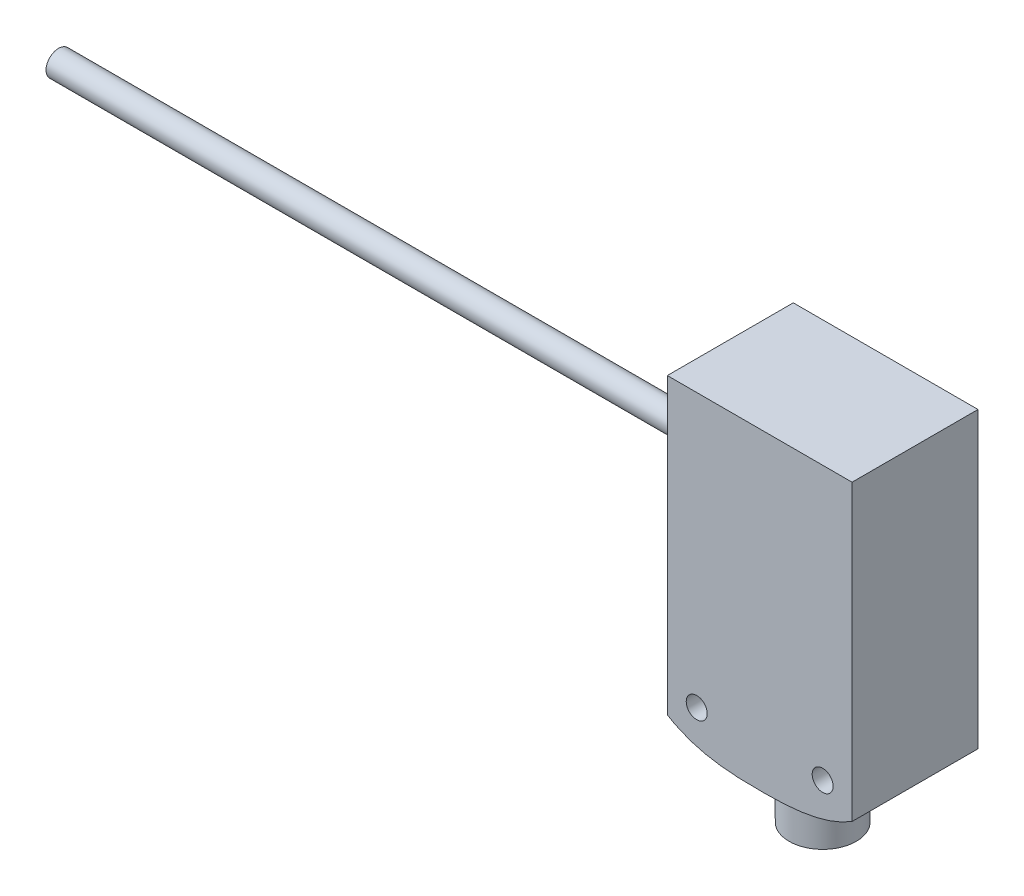
from build123d import *

# Parameters (mm, degrees)
ESQUISSE1_W             = 22
ESQUISSE1_H             = 44.3
ESQUISSE1_R             = 1.25
BOSS_EXTRU_1_DEPTH      = 15
ENL_V_MAT_EXTRU_1_DEPTH = 16
BOSS_EXTRU_2_REACH      = 46.3
ESQUISSE3_R             = 4
ENL_V_MAT_EXTRU_2_DEPTH = 0.1
ESQUISSE5_R             = 1.5
BOSS_EXTRU_3_DEPTH      = 80


with BuildPart() as part:
    # Esquisse1 → Boss.-Extru.1 (new body)
    with BuildSketch(Plane.XY):
        with Locations((0, 22.15)):
            Rectangle(ESQUISSE1_W, ESQUISSE1_H)
        with Locations((7.5, 11.8)):
            Circle(ESQUISSE1_R, mode=Mode.SUBTRACT)
        with Locations((-7.5, 11.8)):
            Circle(ESQUISSE1_R, mode=Mode.SUBTRACT)
    extrude(amount=BOSS_EXTRU_1_DEPTH)

    # Esquisse2 → Enlèv. mat.-Extru.1 (cut, through all)
    with BuildSketch(Plane.XY.offset(15)):
        with BuildLine():
            Line((-11, 9.3), (-11, 0))
            Line((-11, 0), (11, 0))
            Line((11, 0), (11, 9.3))
            add(Edge.make_bspline(
                [(-11, 9.3), (-7.625374572, 7.236730077), (0, 6.763269923), (7.625374572, 7.236730077), (11, 9.3)],
                knots=[0, 0, 0, 0, 0.5, 1, 1, 1, 1], degree=3))
        make_face()
    extrude(amount=-ENL_V_MAT_EXTRU_1_DEPTH, mode=Mode.SUBTRACT)

    # Esquisse3 → Boss.-Extru.2 (add, up to next)
    with BuildSketch(Plane(origin=(0, 0, 0), x_dir=(1, 0, 0), z_dir=(0, 1, 0)), mode=Mode.PRIVATE) as boss_extru_2_sk1:
        with Locations((0, -7.5)):
            Circle(ESQUISSE3_R)
    boss_extru_2_tool1 = extrude(boss_extru_2_sk1.sketch, amount=BOSS_EXTRU_2_REACH, mode=Mode.PRIVATE) - part.part
    add(boss_extru_2_tool1.solids().sort_by_distance((0, 0, 7.5))[0])

    # Esquisse4 → Enlèv. mat.-Extru.2 (cut)
    with BuildSketch(Plane.ZY.offset(11)):
        with BuildLine():
            Line((1.3, 37.8), (13.7, 37.8))
            Line((13.7, 37.8), (13.7, 16.8))
            ThreePointArc((13.7, 16.8), (7.5, 15.814731131), (1.3, 16.8))
            Line((1.3, 16.8), (1.3, 37.8))
        make_face()
    extrude(amount=-ENL_V_MAT_EXTRU_2_DEPTH, mode=Mode.SUBTRACT)


with BuildPart() as body_2:
    # Esquisse5 → Boss.-Extru.3 (new body)
    with BuildSketch(Plane.ZY.offset(11)):
        with Locations((7.5, 32.8)):
            Circle(ESQUISSE5_R)
    extrude(amount=BOSS_EXTRU_3_DEPTH)


solid = Compound([part.part, body_2.part])
